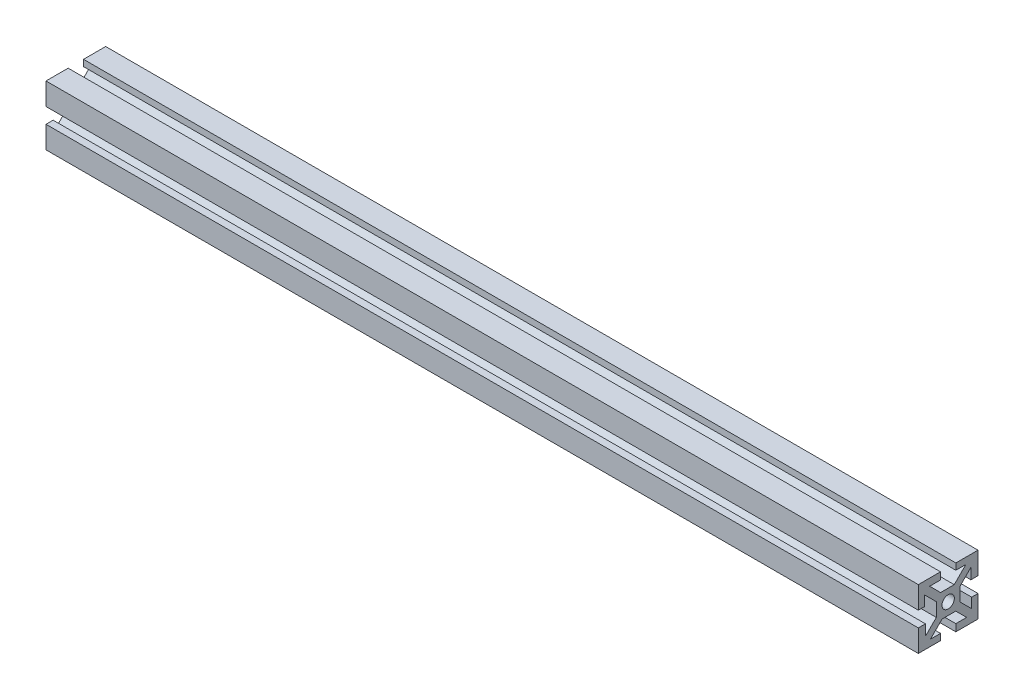
from build123d import *

# Parameters (mm, degrees)
SKETCH1_R           = 2.605
BOSS_EXTRUDE1_DEPTH = 368.3
CIRPATTERN1_COUNT   = 4


with BuildPart() as part:
    # Sketch1 → Boss-Extrude1 (new body)
    with BuildSketch(Plane(origin=(0, 0, 0), x_dir=(0, 0, -1), z_dir=(1, 0, 0))):
        Polygon((5, -5), (5, 3.203948776), (9.596194078, 7.800142853), (9.596194078, 3.24), (12.596194078, 3.24), (12.596194078, 12.596194078), (3.24, 12.596194078), (3.24, 9.921463197), (7.474873734, 9.921463197), (2.553410537, 5), (-5, 5), (-5, -5), align=None)
        Circle(SKETCH1_R, mode=Mode.SUBTRACT)
    boss_extrude1 = extrude(amount=BOSS_EXTRUDE1_DEPTH)

    # CirPattern1: Boss-Extrude1 ×4 about axis
    cirpattern1_axis = Axis((0, 0, 0), (1, 0, 0))
    for i in range(1, CIRPATTERN1_COUNT):
        add(boss_extrude1.rotate(cirpattern1_axis, i * 360 / CIRPATTERN1_COUNT))


solid = part.part
